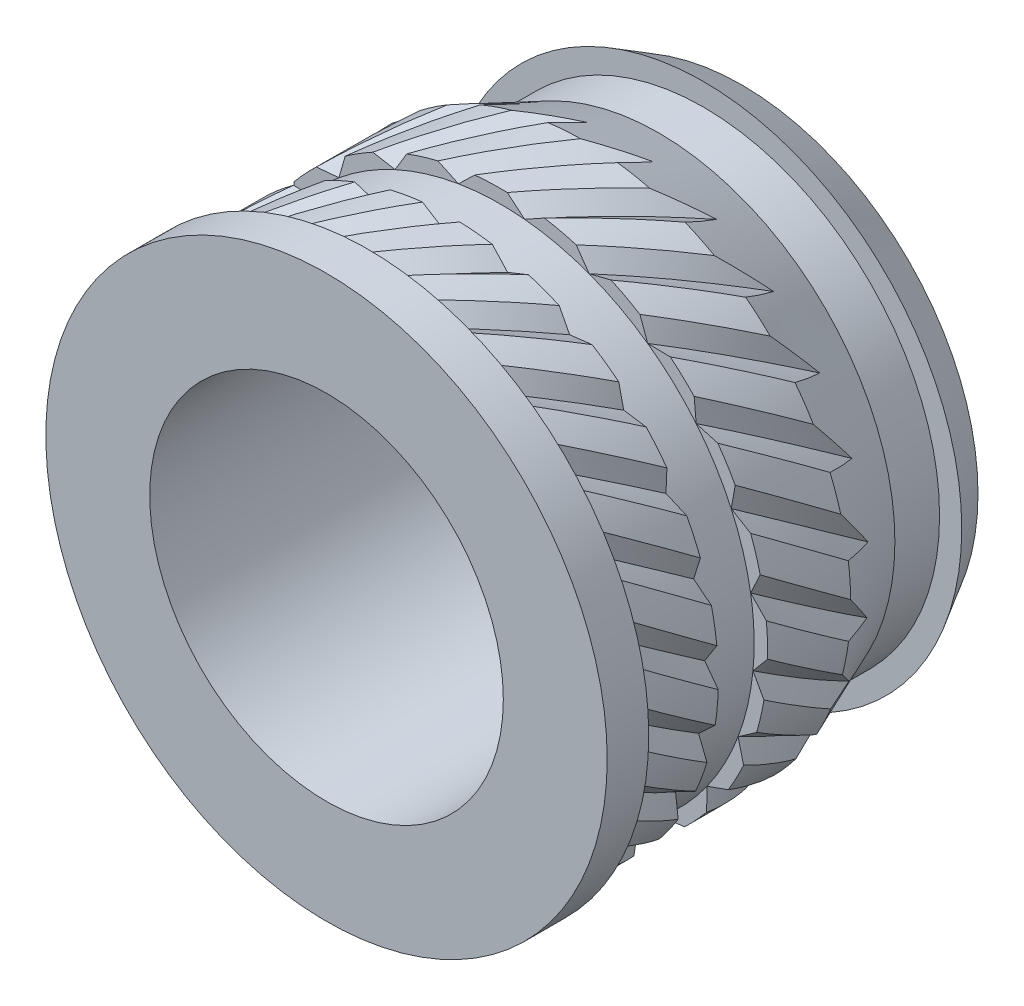
from build123d import *

# Parameters (mm, degrees)
CIRPATTERN1_COUNT = 24


with BuildPart() as part:
    # Sketch3 → Revolve1 (revolve)
    with BuildSketch(Plane(origin=(0, 0, 0), x_dir=(0, 0, -1), z_dir=(1, 0, 0))):
        Polygon((-2.35, 2), (-2.35, 3.175), (-1.88, 3.175), (-1.88, 3.0225), (-0.94, 3.0225), (-0.94, 2.87), (-0.383183073, 2.87), (-0.383183073, 3.0225), (0.556816927, 3.0225), (1.41, 2.6691), (1.915428452, 2.6691), (1.915428452, 2.92), (2.35, 2.6691), (2.35, 2), align=None)
    revolve(axis=Axis((0, 0, 2.35), (0, 0, -1)))

    # Cut-Sweep1: sweep along a curve in space
    with BuildLine() as cut_sweep1_path:
        add(Edge.make_bspline(
            [(0, 3.0225, 1.88), (0.263505453, 3.0225, 1.514801223), (0.791408342, 2.953028126, 0.783119266), (1.528496008, 2.647716418, -0.313119266), (1.950903753, 2.323556739, -1.044801223), (2.137230246, 2.137230246, -1.41)],
            knots=[0, 0, 0, 0, 0.333333333, 0.666666667, 1, 1, 1, 1], degree=3))
    # Sketch5 → Cut-Sweep1 (sweep, cut)
    with BuildSketch(Plane.XY.offset(1.88)):
        with BuildLine():
            Line((-0.224024249, 3.024213846), (0, 2.87))
            Line((0, 2.87), (0.224024249, 3.024213846))
            ThreePointArc((0.224024249, 3.024213846), (0, 3.0325), (-0.224024249, 3.024213846))
        make_face()
    cut_sweep1 = sweep(path=cut_sweep1_path.line, is_frenet=True, mode=Mode.SUBTRACT)

    # CirPattern1: Cut-Sweep1 ×24 about axis
    cirpattern1_axis = Axis((0, 0, 2.35), (0, 0, -1))
    for i in range(1, CIRPATTERN1_COUNT):
        add(cut_sweep1.rotate(cirpattern1_axis, i * 360 / CIRPATTERN1_COUNT), mode=Mode.SUBTRACT)


solid = part.part
